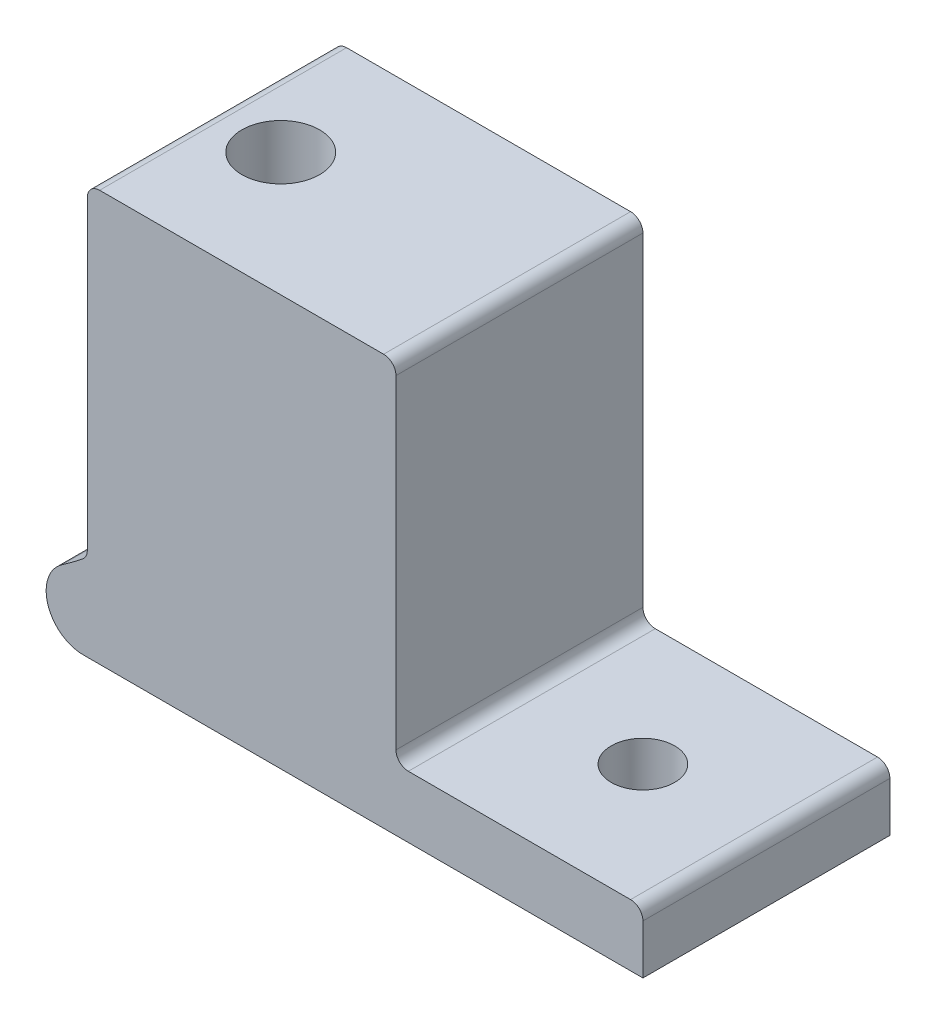
from build123d import *

# Parameters (mm, degrees)
BOSS_EXTRUDE1_DEPTH     = 12.7
SKETCH2_R               = 3.2639
CUT_EXTRUDE1_DEPTH      = 4.23
CUT_EXTRUDE1_DEPTH_BACK = 40
SKETCH3_R               = 4
CUT_EXTRUDE2_DEPTH      = 31.75
SKETCH4_W               = 3.1115
SKETCH4_H               = 42.23
BOSS_EXTRUDE2_DEPTH     = 31.75
FILLET4_R               = 1.27


with BuildPart() as part:
    # Sketch1 → Boss-Extrude1 (new body, symmetric)
    with BuildSketch(Plane.XY):
        with BuildLine():
            Line((81.95454797, -39), (81.95454797, -32.65))
            Line((81.95454797, -32.65), (56.55454797, -32.65))
            Line((56.55454797, -32.65), (56.55454797, 3.23))
            Line((56.55454797, 3.23), (24.80454797, 3.23))
            Line((24.80454797, 3.23), (24.80454797, -3.12))
            Line((24.80454797, -3.12), (38.874999678, -3.12))
            ThreePointArc((38.874999678, -3.12), (33.796327751, -19.462996443), (22.209775375, -32.05816398))
            ThreePointArc((22.209775375, -32.05816398), (20.742990597, -36.326618838), (24.379499585, -39))
            Line((24.379499585, -39), (81.95454797, -39))
        make_face()
    extrude(amount=BOSS_EXTRUDE1_DEPTH, both=True)

    # Sketch2 → Cut-Extrude1 (cut, two sides)
    with BuildSketch(Plane(origin=(0, 0, 0), x_dir=(1, 0, 0), z_dir=(0, 1, 0))) as cut_extrude1_sk:
        with Locations((69.25454797, 0)):
            Circle(SKETCH2_R)
    extrude(amount=CUT_EXTRUDE1_DEPTH, mode=Mode.SUBTRACT)
    extrude(cut_extrude1_sk.sketch, amount=-CUT_EXTRUDE1_DEPTH_BACK, mode=Mode.SUBTRACT)

    # Sketch3 → Cut-Extrude2 (cut)
    with BuildSketch(Plane(origin=(0, 3.23, 0), x_dir=(1, 0, 0), z_dir=(0, 1, 0))):
        with Locations((32, 0)):
            Circle(SKETCH3_R)
    extrude(amount=-CUT_EXTRUDE2_DEPTH, mode=Mode.SUBTRACT)

    # Sketch4 → Boss-Extrude2 (add)
    with BuildSketch(Plane.ZY.offset(-24.80454797)):
        with Locations((-11.14425, -17.885)):
            Rectangle(SKETCH4_W, SKETCH4_H)
        with Locations((11.14425, -17.885)):
            Rectangle(SKETCH4_W, SKETCH4_H)
    extrude(amount=-BOSS_EXTRUDE2_DEPTH)

    # Fillet4
    fillet4_edges = [part.edges().sort_by_distance(p)[0] for p in [
        (24.80454797, 3.23, 0),
        (56.55454797, 3.23, 0),
        (56.55454797, -32.65, 0),
        (81.95454797, -32.65, 0),
        (24.80454797, -30.095421579, -11.14425),
        (24.80454797, -30.095421579, 11.14425),
    ]]
    fillet(fillet4_edges, radius=FILLET4_R)


solid = part.part
